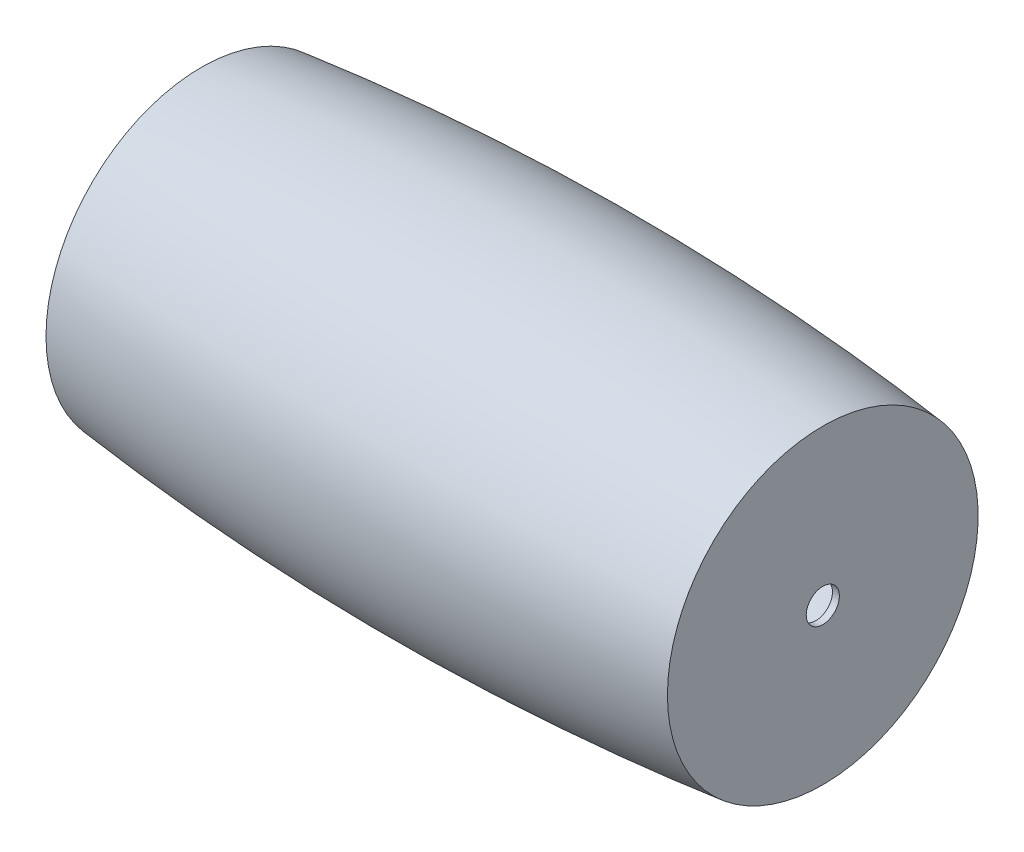
from build123d import *

# Parameters (mm, degrees)
SKETCH_2_R          = 24
CUT_EXTRUDE_1_DEPTH = 901.0000001


with BuildPart() as part:
    # Эскиз1 → Повернуть1 (revolve)
    with BuildSketch(Plane.XY):
        with BuildLine():
            Line((0, 21.920416175), (0, 31.9824899))
            ThreePointArc((0, 31.9824899), (450, 56.9824899), (900, 31.9824899))
            Line((900, 31.9824899), (900, -193.0175101))
            Line((900, -193.0175101), (890, -193.0175101))
            Line((890, -193.0175101), (890, 23.025185466))
            ThreePointArc((890, 23.025185466), (444.96957966, 46.979367736), (0, 21.920416175))
        make_face()
    revolve(axis=Axis((890, -193.0175101, 0), (1, 0, 0)))

    # Эскиз2 → Вырез-Вытянуть1 (cut, through all)
    with BuildSketch(Plane.ZY):
        with Locations((0, -193.0175101)):
            Circle(SKETCH_2_R)
    extrude(amount=-CUT_EXTRUDE_1_DEPTH, mode=Mode.SUBTRACT)


solid = part.part
